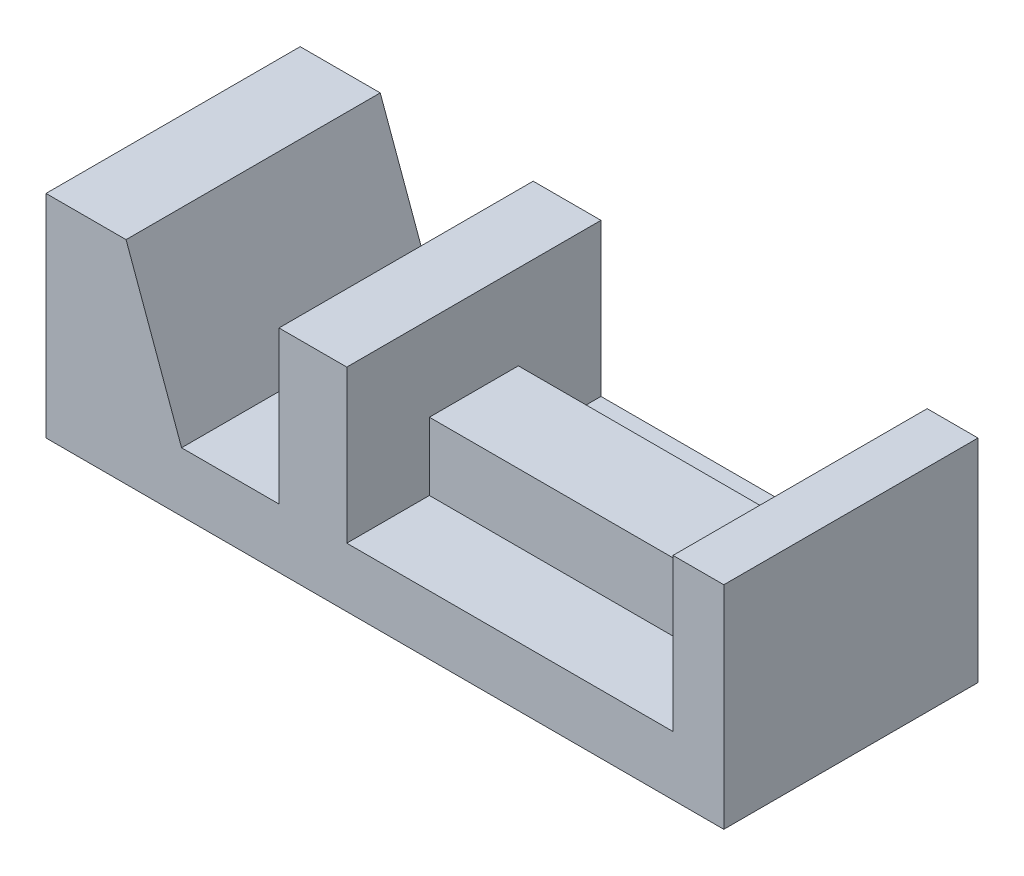
from build123d import *

# Parameters (mm, degrees)
BOSS_EXTRUDE1_DEPTH = 60
SKETCH3_W           = 77
SKETCH3_H           = 21
BOSS_EXTRUDE2_DEPTH = 16


with BuildPart() as part:
    # Sketch2 → Boss-Extrude1 (new body)
    with BuildSketch(Plane.XY):
        Polygon((0, 0), (0, 50), (18.897071566, 50), (32, 14), (55, 14), (55, 50), (71, 50), (71, 14), (148, 14), (148, 50), (160, 50), (160, 0), align=None)
    extrude(amount=BOSS_EXTRUDE1_DEPTH)

    # Sketch3 → Boss-Extrude2 (add)
    with BuildSketch(Plane(origin=(0, 14, 0), x_dir=(1, 0, 0), z_dir=(0, 1, 0))):
        with Locations((109.5, -30)):
            Rectangle(SKETCH3_W, SKETCH3_H)
    extrude(amount=BOSS_EXTRUDE2_DEPTH)


solid = part.part
